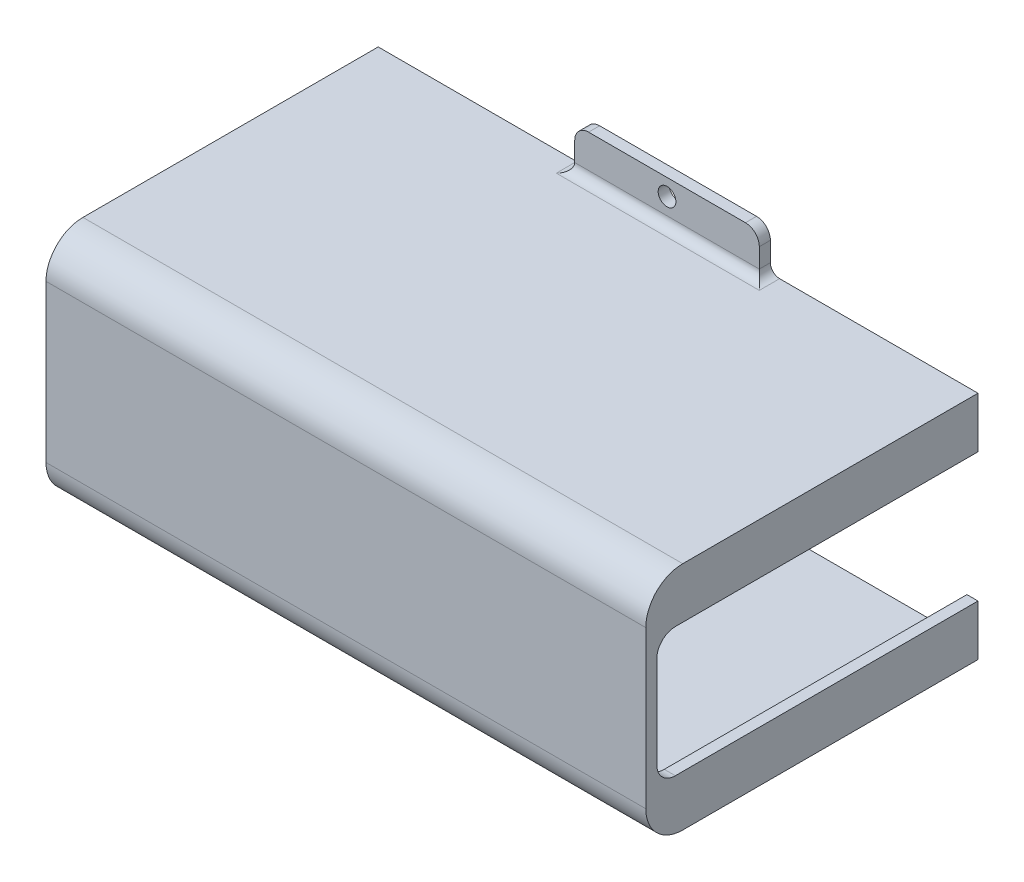
from build123d import *

# Parameters (mm, degrees)
SKETCH1_W               = 82.55
SKETCH1_H               = 31.75
BOSS_EXTRUDE1_DEPTH     = 45.72
SHELL1_T                = -1.524
SKETCH3_W               = 25.4
SKETCH3_H               = 5.842
BOSS_EXTRUDE3_DEPTH     = 1.524
FILLET2_R               = 1.27
FILLET3_R               = 1.905
F_2_CLEARANCE_HOLE1_D   = 2.4384
SKETCH6_W               = 44.196
SKETCH6_H               = 28.702
CUT_EXTRUDE1_DEPTH      = 82.026
CUT_EXTRUDE1_DEPTH_BACK = 2.524
FILLET4_R               = 3.556
FILLET5_R               = 5.08
BOSS_EXTRUDE4_DEPTH     = 1.524
FILLET9_R               = 2.54
FILLET10_R              = 2.54


with BuildPart() as part:
    # Sketch1 → Boss-Extrude1 (new body)
    with BuildSketch(Plane.XY):
        Rectangle(SKETCH1_W, SKETCH1_H)
    extrude(amount=BOSS_EXTRUDE1_DEPTH)

    # Shell1
    shell1_openings = [part.faces().sort_by_distance(p)[0] for p in [
        (0, 0, 0),
    ]]
    offset(amount=SHELL1_T, openings=shell1_openings, kind=Kind.INTERSECTION)

    # Sketch3 → Boss-Extrude3 (add)
    with BuildSketch(Plane(origin=(0, 0, 0), x_dir=(-1, 0, 0), z_dir=(0, 0, -1))):
        with Locations((0, 18.796)):
            Rectangle(SKETCH3_W, SKETCH3_H)
        with Locations((0, -18.796)):
            Rectangle(SKETCH3_W, SKETCH3_H)
    extrude(amount=-BOSS_EXTRUDE3_DEPTH)

    # Fillet2
    fillet2_edges = [part.edges().sort_by_distance(p)[0] for p in [
        (12.7, 15.875, 0.762),
        (0, 15.875, 1.524),
        (-12.7, 15.875, 0.762),
        (0, -15.875, 1.524),
        (12.7, -15.875, 0.762),
        (-12.7, -15.875, 0.762),
    ]]
    fillet(fillet2_edges, radius=FILLET2_R)

    # Fillet3
    fillet3_edges = [part.edges().sort_by_distance(p)[0] for p in [
        (12.7, 21.717, 0.762),
        (-12.7, 21.717, 0.762),
        (12.7, -21.717, 0.762),
        (-12.7, -21.717, 0.762),
    ]]
    fillet(fillet3_edges, radius=FILLET3_R)

    # #2 Clearance Hole1 (through all)
    with Locations(Plane.XY.offset(1.524)):
        with Locations((0, 19.431), (0, -19.431)):
            Hole(F_2_CLEARANCE_HOLE1_D / 2)

    # Sketch6 → Cut-Extrude1 (cut, two sides)
    with BuildSketch(Plane(origin=(-39.751, 0, 0), x_dir=(0, 0, -1), z_dir=(1, 0, 0))) as cut_extrude1_sk:
        with Locations((-22.098, 0)):
            Rectangle(SKETCH6_W, SKETCH6_H)
    extrude(amount=CUT_EXTRUDE1_DEPTH, mode=Mode.SUBTRACT)
    extrude(cut_extrude1_sk.sketch, amount=-CUT_EXTRUDE1_DEPTH_BACK, mode=Mode.SUBTRACT)

    # Fillet4
    fillet4_edges = [part.edges().sort_by_distance(p)[0] for p in [
        (0, -14.351, 44.196),
        (0, 14.351, 44.196),
    ]]
    fillet(fillet4_edges, radius=FILLET4_R)

    # Fillet5
    fillet5_edges = [part.edges().sort_by_distance(p)[0] for p in [
        (0, 15.875, 45.72),
        (0, -15.875, 45.72),
    ]]
    fillet(fillet5_edges, radius=FILLET5_R)

    # Sketch7 → Boss-Extrude4 (add)
    with BuildSketch(Plane(origin=(41.275, 0, 0), x_dir=(0, 0, -1), z_dir=(1, 0, 0))):
        with BuildLine():
            Line((-45.72, 10.795), (-45.72, -10.795))
            ThreePointArc((-45.72, -10.795), (-44.232102448, -14.387102448), (-40.64, -15.875))
            Line((-40.64, -15.875), (0, -15.875))
            Line((0, -15.875), (0, -8.89))
            Line((0, -8.89), (-44.196, -8.89))
            Line((-44.196, -8.89), (-44.196, 8.89))
            Line((-44.196, 8.89), (0, 8.89))
            Line((0, 8.89), (0, 15.875))
            Line((0, 15.875), (-40.64, 15.875))
            ThreePointArc((-40.64, 15.875), (-44.232102448, 14.387102448), (-45.72, 10.795))
        make_face()
    boss_extrude4 = extrude(amount=-BOSS_EXTRUDE4_DEPTH)

    # Fillet9
    fillet9_edges = [part.edges().sort_by_distance(p)[0] for p in [
        (40.513, 8.89, 44.196),
        (40.513, -8.89, 44.196),
    ]]
    fillet(fillet9_edges, radius=FILLET9_R)

    # Mirror1: Boss-Extrude4 across plane
    add(boss_extrude4.mirror(Plane(origin=(0, 0, 0), x_dir=(0, 0, 1), z_dir=(1, 0, 0))))

    # Fillet10
    fillet10_edges = [part.edges().sort_by_distance(p)[0] for p in [
        (-40.513, -8.89, 44.196),
        (-40.513, 8.89, 44.196),
    ]]
    fillet(fillet10_edges, radius=FILLET10_R)


solid = part.part
